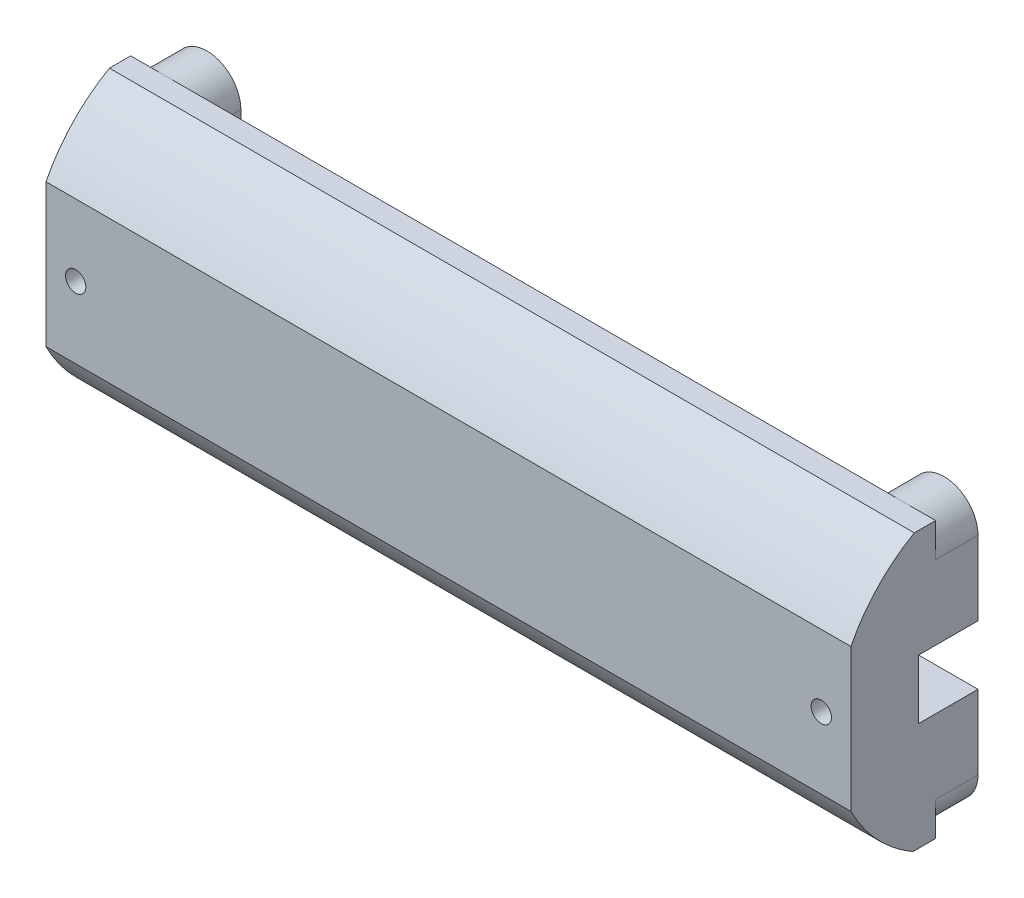
from build123d import *

# Parameters (mm, degrees)
SKETCH1_R             = 4
SKETCH1_R_2           = 1.5
BOSS_EXTRUDE1_DEPTH   = 5
BOSS_EXTRUDE1_2_DEPTH = 5
BOSS_EXTRUDE1_3_DEPTH = 5
BOSS_EXTRUDE1_4_DEPTH = 5
SKETCH2_W             = 95
SKETCH2_H             = 32.5
BOSS_EXTRUDE2_DEPTH   = 10
SKETCH3_W             = 45
SKETCH3_H             = 14.2
CUT_EXTRUDE1_DEPTH    = 9
SKETCH4_W             = 5
SKETCH4_H             = 14.2
SKETCH4_W_2           = 45
CUT_EXTRUDE2_DEPTH    = 4
SKETCH5_R             = 1.4
SKETCH5_R_2           = 1.6
CUT_EXTRUDE3_DEPTH    = 5
BOSS_EXTRUDE3_DEPTH   = 5
CUT_EXTRUDE5_DEPTH    = 96
SKETCH9_W             = 7
SKETCH9_H             = 7
CUT_EXTRUDE6_DEPTH    = 96
SKETCH10_R            = 1.2
CUT_EXTRUDE7_DEPTH    = 16


with BuildPart() as part:
    # Sketch1 → Boss-Extrude1 (new body)
    with BuildSketch(Plane.XY):
        with Locations((-43.5, -12.25)):
            Circle(SKETCH1_R)
        with Locations((-43.5, -12.25)):
            Circle(SKETCH1_R_2, mode=Mode.SUBTRACT)
    extrude(amount=BOSS_EXTRUDE1_DEPTH)



with BuildPart() as body_2:
    # Sketch1 → Boss-Extrude1 2 (new body)
    with BuildSketch(Plane.XY):
        with Locations((-43.5, 12.25)):
            Circle(SKETCH1_R)
        with Locations((-43.5, 12.25)):
            Circle(SKETCH1_R_2, mode=Mode.SUBTRACT)
    extrude(amount=BOSS_EXTRUDE1_2_DEPTH)


with BuildPart() as body_3:
    # Sketch1 → Boss-Extrude1 3 (new body)
    with BuildSketch(Plane.XY):
        with Locations((43.5, -12.25)):
            Circle(SKETCH1_R)
        with Locations((43.5, -12.25)):
            Circle(SKETCH1_R_2, mode=Mode.SUBTRACT)
    extrude(amount=BOSS_EXTRUDE1_3_DEPTH)


with BuildPart() as body_4:
    # Sketch1 → Boss-Extrude1 4 (new body)
    with BuildSketch(Plane.XY):
        with Locations((43.5, 12.25)):
            Circle(SKETCH1_R)
        with Locations((43.5, 12.25)):
            Circle(SKETCH1_R_2, mode=Mode.SUBTRACT)
    extrude(amount=BOSS_EXTRUDE1_4_DEPTH)


with BuildPart() as part_1:
    add(part.part)

    add(body_2.part)  # Boss-Extrude2 merges body 2

    add(body_3.part)  # Boss-Extrude2 merges body 3

    add(body_4.part)  # Boss-Extrude2 merges body 4
    # Sketch2 → Boss-Extrude2 (add)
    with BuildSketch(Plane.XY.offset(5)):
        Rectangle(SKETCH2_W, SKETCH2_H)
    extrude(amount=BOSS_EXTRUDE2_DEPTH)

    # Sketch3 → Cut-Extrude1 (cut)
    with BuildSketch(Plane(origin=(0, 0, 5), x_dir=(-1, 0, 0), z_dir=(0, 0, -1))):
        Rectangle(SKETCH3_W, SKETCH3_H)
    extrude(amount=-CUT_EXTRUDE1_DEPTH, mode=Mode.SUBTRACT)

    # Sketch4 → Cut-Extrude2 (cut)
    with BuildSketch(Plane(origin=(0, 0, 5), x_dir=(-1, 0, 0), z_dir=(0, 0, -1))):
        with Locations((-25, 0)):
            Rectangle(SKETCH4_W, SKETCH4_H)
        Rectangle(SKETCH4_W_2, SKETCH4_H)
        with Locations((25, 0)):
            Rectangle(SKETCH4_W, SKETCH4_H)
    extrude(amount=-CUT_EXTRUDE2_DEPTH, mode=Mode.SUBTRACT)

    # Sketch5 → Cut-Extrude3 (cut)
    with BuildSketch(Plane(origin=(0, 0, 9), x_dir=(-1, 0, 0), z_dir=(0, 0, -1))):
        with Locations((-24.8, -0.2)):
            Circle(SKETCH5_R)
        with Locations((24.8, -0.2)):
            Circle(SKETCH5_R_2)
    extrude(amount=-CUT_EXTRUDE3_DEPTH, mode=Mode.SUBTRACT)

    # Sketch6 → Boss-Extrude3 (add)
    with BuildSketch(Plane(origin=(0, 0, 5), x_dir=(-1, 0, 0), z_dir=(0, 0, -1))):
        with BuildLine():
            ThreePointArc((47.5, 12.25), (43.5, 8.25), (39.5, 12.25))
            Line((39.5, 12.25), (39.5, -12.25))
            ThreePointArc((39.5, -12.25), (43.5, -8.25), (47.5, -12.25))
            Line((47.5, -12.25), (47.5, 12.25))
        make_face()
        with BuildLine():
            ThreePointArc((-39.5, 12.25), (-43.5, 8.25), (-47.5, 12.25))
            Line((-47.5, 12.25), (-47.5, -12.25))
            ThreePointArc((-47.5, -12.25), (-43.5, -8.25), (-39.5, -12.25))
            Line((-39.5, -12.25), (-39.5, 12.25))
        make_face()
    extrude(amount=BOSS_EXTRUDE3_DEPTH)

    # Sketch8 → Cut-Extrude5 (cut, through all)
    with BuildSketch(Plane(origin=(47.5, 0, 0), x_dir=(0, 0, -1), z_dir=(1, 0, 0))):
        with BuildLine():
            ThreePointArc((-15, 8.377014021), (-11.841659381, 12.867099577), (-7.518238456, 16.25))
            Line((-7.518238456, 16.25), (-15, 16.25))
            Line((-15, 16.25), (-15, 8.377014021))
        make_face()
        with BuildLine():
            Line((-15, -16.25), (-7.688934819, -16.25))
            ThreePointArc((-7.688934819, -16.25), (-11.909309532, -12.893789895), (-15, -8.475267356))
            Line((-15, -8.475267356), (-15, -16.25))
        make_face()
    extrude(amount=-CUT_EXTRUDE5_DEPTH, mode=Mode.SUBTRACT)

    # Sketch9 → Cut-Extrude6 (cut, through all)
    with BuildSketch(Plane.ZY.offset(47.5)):
        with Locations((3.5, 0)):
            Rectangle(SKETCH9_W, SKETCH9_H)
    extrude(amount=-CUT_EXTRUDE6_DEPTH, mode=Mode.SUBTRACT)

    # Sketch10 → Cut-Extrude7 (cut, through all)
    with BuildSketch(Plane.XY.offset(15)):
        with Locations((-44, -0.049126667)):
            Circle(SKETCH10_R)
        with Locations((44, -0.049126667)):
            Circle(SKETCH10_R)
    extrude(amount=-CUT_EXTRUDE7_DEPTH, mode=Mode.SUBTRACT)


solid = part_1.part
